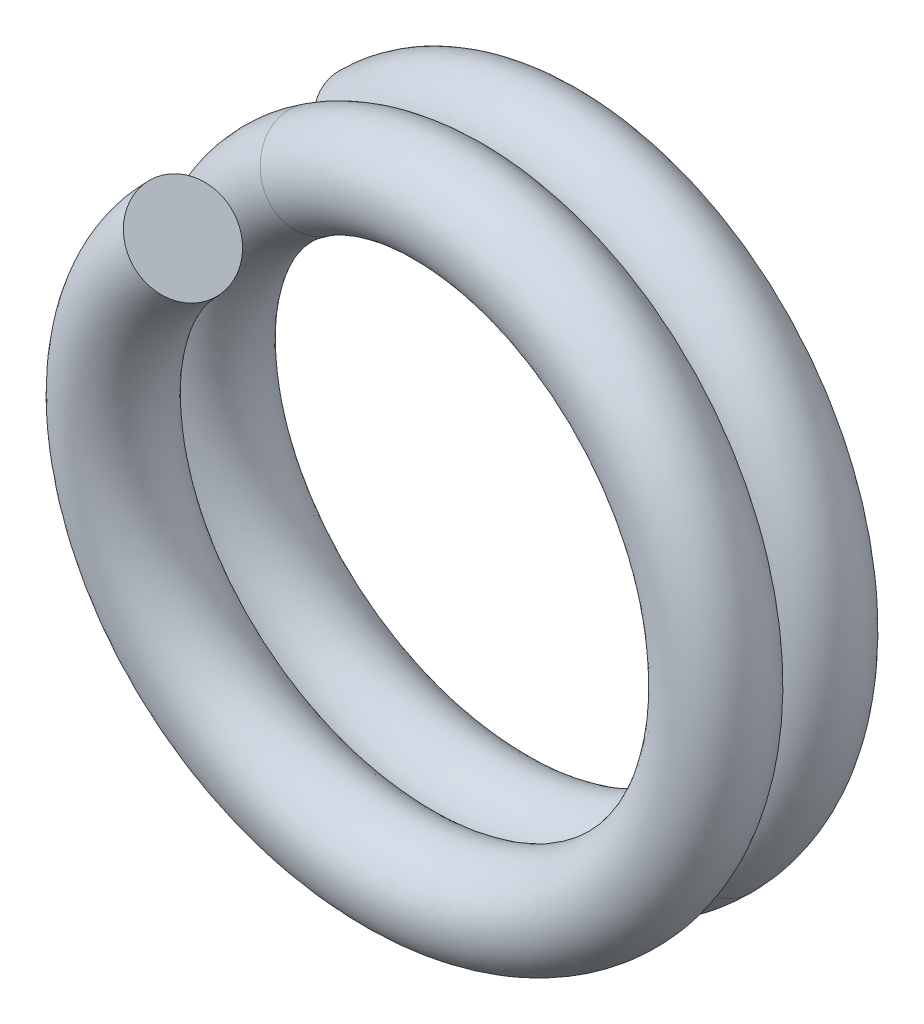
from build123d import *

# Parameters (mm, degrees)
SWEEP1_PITCH       = 3
SWEEP1_HEIGHT      = 6
SWEEP1_RADIUS      = 8.75
SWEEP1_START_ANGLE = 135
SWEEP1_PROFILE_R   = 1.5


with BuildPart() as part:
    # Sweep1: sweep along a helix
    with BuildLine() as sweep1_path:
        add(Helix(SWEEP1_PITCH, SWEEP1_HEIGHT, SWEEP1_RADIUS, center=(0, 0, 0), direction=(0, 0, 1), lefthand=True, mode=Mode.PRIVATE).rotate(Axis((0, 0, 0), (0, 0, 1)), SWEEP1_START_ANGLE))
    # Sweep1 profile (on start of the path) → Sweep1 (sweep)
    with BuildSketch(Plane(origin=(-6.187184335, 6.187184335, 0), x_dir=(0.707106781, -0.707106781, 0), z_dir=(0.706056385, 0.706056385, 0.05448635))):
        Circle(SWEEP1_PROFILE_R)
    sweep(path=sweep1_path.line, is_frenet=True)


solid = part.part
